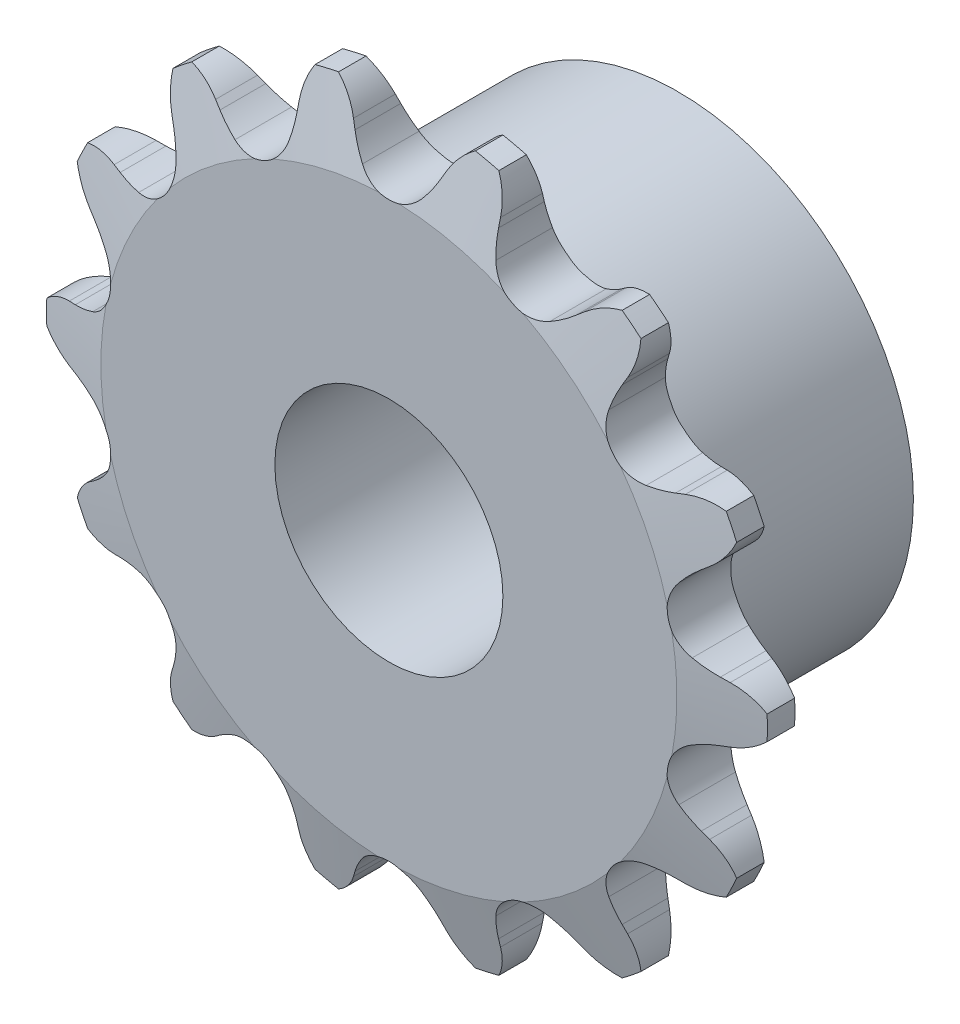
from build123d import *

# Parameters (mm, degrees)
TOOTH_CUT_NUMBER_OF_TEETH_14_DEPTH = 23.410198508
TOOTH_PATTERN_14_14_COUNT          = 14
SKETCH3_W                          = 9.906
SKETCH3_H                          = 10.31875
CUT_EXTRUDE1_DEPTH                 = 25.879893202
CUT_EXTRUDE1_DEPTH_BACK            = 25.879893202
SKETCH4_R                          = 5.0038


with BuildPart() as part:
    # Sprocket-BaseSketch → 25 _04C_ ANSI _ISO_ Chain Number_ 1.123i (revolve)
    with BuildSketch(Plane(origin=(0, 0, 0), x_dir=(0, 0, -1), z_dir=(1, 0, 0))):
        Polygon((1.397, 0), (1.397, 12.640583899), (0.60325, 15.815583899), (-0.60325, 15.815583899), (-1.397, 12.640583899), (-1.397, 0), align=None)
    revolve(axis=Axis((0, 0, -5.588), (0, 0, 1)))

    # Tooth-Sketch → Tooth-Cut_ Number of teeth_ 14 (cut, symmetric)
    with BuildSketch(Plane.XY):
        with BuildLine():
            Line((1.878642309, 14.08764126), (2.030645468, 14.409414052))
            ThreePointArc((2.030645468, 14.409414052), (3.041188348, 15.553060656), (4.506896752, 15.978293933))
            ThreePointArc((4.506896752, 15.978293933), (0, 16.601746756), (-4.506896752, 15.978293933))
            ThreePointArc((-4.506896752, 15.978293933), (-3.041188348, 15.553060656), (-2.030645468, 14.409414052))
            Line((-2.030645468, 14.409414052), (-1.878642309, 14.08764126))
            ThreePointArc((-1.878642309, 14.08764126), (-1.623537626, 13.62333338), (-1.313749559, 13.19357582))
            ThreePointArc((-1.313749559, 13.19357582), (0, 12.570965484), (1.313749559, 13.19357582))
            ThreePointArc((1.313749559, 13.19357582), (1.623537626, 13.62333338), (1.878642309, 14.08764126))
        make_face()
    tooth_cut_number_of_teeth_14 = extrude(amount=TOOTH_CUT_NUMBER_OF_TEETH_14_DEPTH, both=True, mode=Mode.SUBTRACT)

    # Tooth Pattern_ 14 _ 14: Tooth-Cut_ Number of teeth_ 14 ×14 about axis
    tooth_pattern_14_14_axis = Axis((0, 0, -88.99), (0, 0, 1))
    for i in range(1, TOOTH_PATTERN_14_14_COUNT):
        add(tooth_cut_number_of_teeth_14.rotate(tooth_pattern_14_14_axis, i * 360 / TOOTH_PATTERN_14_14_COUNT), mode=Mode.SUBTRACT)

    # Sketch3 → Hub-Revolve1 (revolve)
    with BuildSketch(Plane(origin=(0, 0, 0), x_dir=(0, 0, -1), z_dir=(1, 0, 0))):
        with Locations((6.35, 5.159375)):
            Rectangle(SKETCH3_W, SKETCH3_H)
    revolve(axis=Axis((0, 0, 9.906), (0, 0, -1)))

    # Sketch4 → Cut-Extrude1 (cut, two sides: drawn at the far end of the back side and taken through both)
    with BuildSketch(Plane.XY.offset(-CUT_EXTRUDE1_DEPTH_BACK)):
        Circle(SKETCH4_R)
    extrude(amount=CUT_EXTRUDE1_DEPTH + CUT_EXTRUDE1_DEPTH_BACK, mode=Mode.SUBTRACT)


solid = part.part
